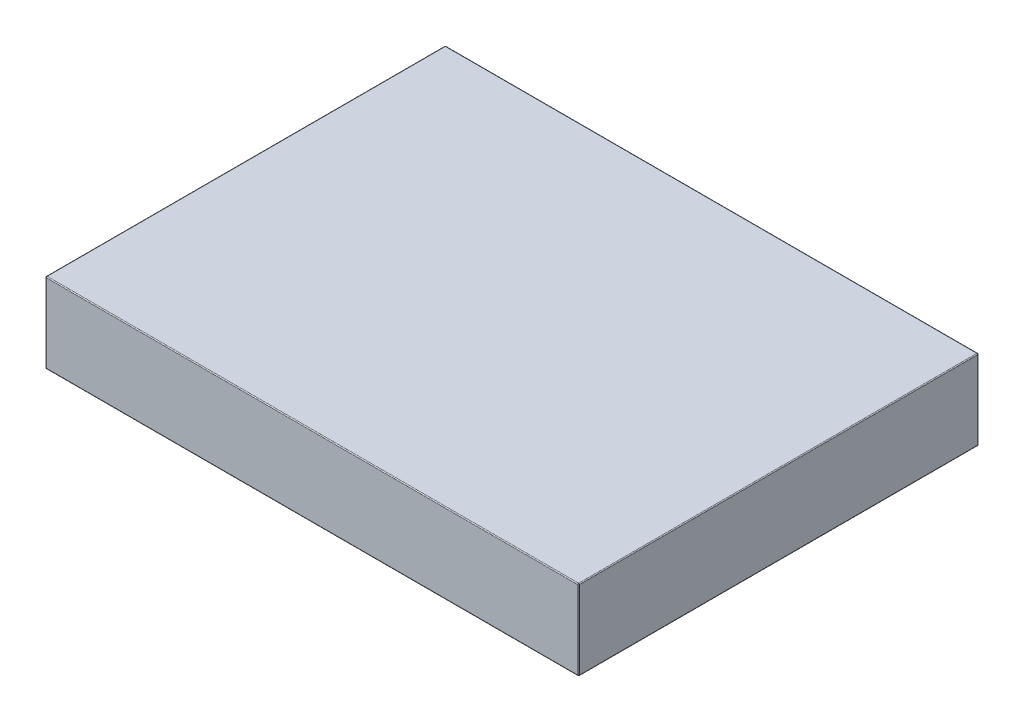
from build123d import *

# Parameters (mm, degrees)
SKETCH1_W           = 152.4
SKETCH1_H           = 114.3
BOSS_EXTRUDE1_DEPTH = 11.43
FILLET1_R           = 0.254


with BuildPart() as part:
    # Sketch1 → Boss-Extrude1 (new body, symmetric)
    with BuildSketch(Plane(origin=(0, 0, 0), x_dir=(1, 0, 0), z_dir=(0, 1, 0))):
        Rectangle(SKETCH1_W, SKETCH1_H)
    extrude(amount=BOSS_EXTRUDE1_DEPTH, both=True)

    # Fillet1
    fillet1_edges = [part.edges().sort_by_distance(p)[0] for p in [
        (-76.2, 11.43, 0),
        (0, 11.43, 57.15),
        (76.2, 11.43, 0),
        (0, -11.43, 57.15),
        (-76.2, -11.43, 0),
        (0, -11.43, -57.15),
        (76.2, -11.43, 0),
        (76.2, 0, 57.15),
        (-76.2, 0, 57.15),
        (-76.2, 0, -57.15),
        (76.2, 0, -57.15),
        (0, 11.43, -57.15),
    ]]
    fillet(fillet1_edges, radius=FILLET1_R)


solid = part.part
